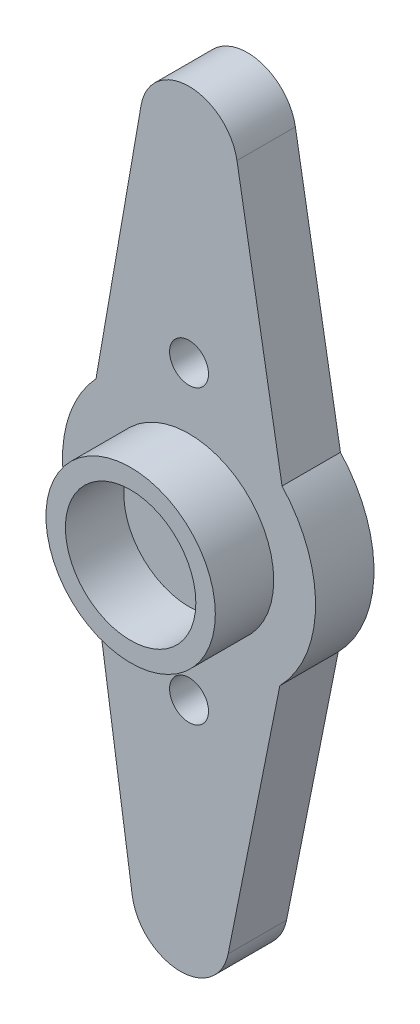
from build123d import *

# Parameters (mm, degrees)
SKETCH_1_R        = 1
EXTRUDE_1_DEPTH   = 3
SKETCH_2_R        = 4.35
SKETCH_2_R_2      = 3.35
EXTRUDE_1_2_DEPTH = 3


with BuildPart() as part:
    # 草图1 → Extrude 1 (new body)
    with BuildSketch(Plane.XY):
        with BuildLine():
            Line((-2.463104237, 17.727922325), (-4.777267611, 4.407688076))
            ThreePointArc((-4.777267611, 4.407688076), (-6.49946928, 0.083060663), (-4.888346081, -4.284165332))
            Line((-4.888346081, -4.284165332), (-2.915337598, -17.659187952))
            ThreePointArc((-2.915337598, -17.659187952), (-0.505989798, -19.793533649), (2.009262058, -17.785077409))
            Line((2.009262058, -17.785077409), (4.663068788, -4.528331865))
            ThreePointArc((4.663068788, -4.528331865), (6.49946928, -0.083060663), (4.777267611, 4.407688076))
            Line((4.777267611, 4.407688076), (2.463104237, 17.727922325))
            ThreePointArc((2.463104237, 17.727922325), (0, 19.8), (-2.463104237, 17.727922325))
        make_face()
        with Locations((0, 7.5)):
            Circle(SKETCH_1_R, mode=Mode.SUBTRACT)
        with Locations((0, -7.5)):
            Circle(SKETCH_1_R, mode=Mode.SUBTRACT)
    extrude(amount=EXTRUDE_1_DEPTH)

    # 草图2 → Extrude 1 2 (add)
    with BuildSketch(Plane.XY.offset(3)):
        Circle(SKETCH_2_R)
        Circle(SKETCH_2_R_2, mode=Mode.SUBTRACT)
    extrude(amount=EXTRUDE_1_2_DEPTH)


solid = part.part
